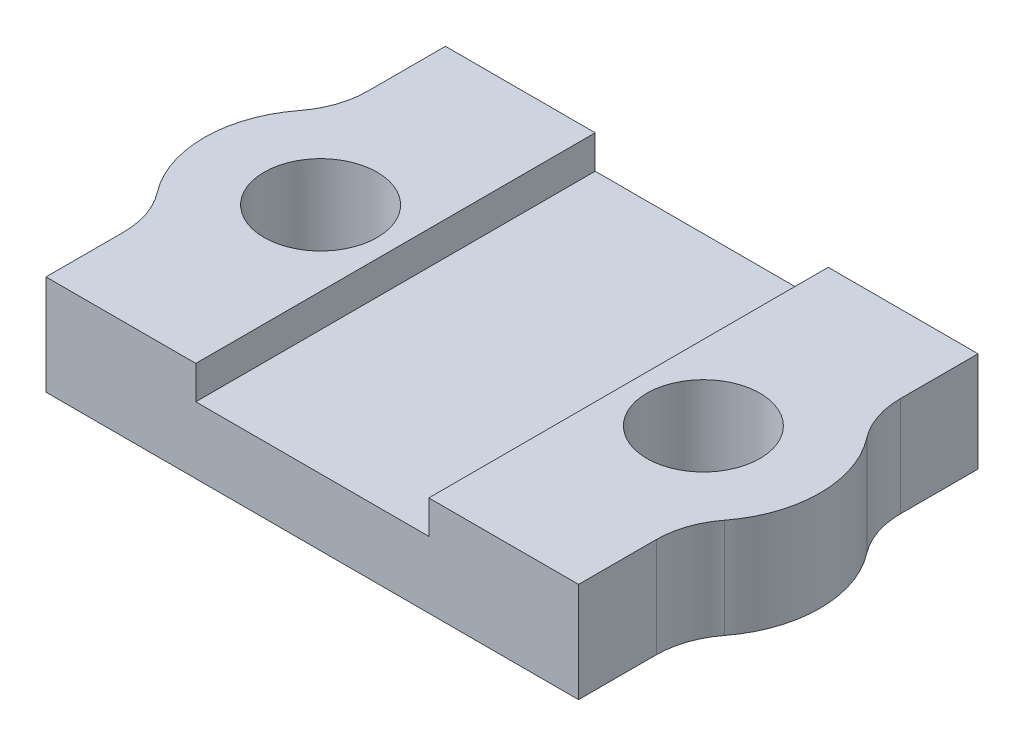
from build123d import *

# Parameters (mm, degrees)
CROQUIS1_R              = 1.7
SALIENTE_EXTRUIR1_DEPTH = 2
CROQUIS5_R              = 1.7
SALIENTE_EXTRUIR3_DEPTH = 1


with BuildPart() as part:
    # Croquis1 → Saliente-Extruir1 (new body)
    with BuildSketch(Plane(origin=(0, 0, 0), x_dir=(1, 0, 0), z_dir=(0, 1, 0))):
        with BuildLine():
            Line((-8, 6), (8, 6))
            Line((8, 6), (8, 3.665719575))
            ThreePointArc((8, 3.665719575), (8.133788189, 2.858848044), (8.520833333, 2.138336419))
            ThreePointArc((8.520833333, 2.138336419), (9.25, 0), (8.520833333, -2.138336419))
            ThreePointArc((8.520833333, -2.138336419), (8.133788189, -2.858848044), (8, -3.665719575))
            Line((8, -3.665719575), (8, -6))
            Line((8, -6), (-8, -6))
            Line((-8, -6), (-8, -3.665719575))
            ThreePointArc((-8, -3.665719575), (-8.133788189, -2.858848044), (-8.520833333, -2.138336419))
            ThreePointArc((-8.520833333, -2.138336419), (-9.25, 0), (-8.520833333, 2.138336419))
            ThreePointArc((-8.520833333, 2.138336419), (-8.133788189, 2.858848044), (-8, 3.665719575))
            Line((-8, 3.665719575), (-8, 6))
        make_face()
        with Locations((5.75, 0)):
            Circle(CROQUIS1_R, mode=Mode.SUBTRACT)
        with Locations((-5.75, 0)):
            Circle(CROQUIS1_R, mode=Mode.SUBTRACT)
    extrude(amount=SALIENTE_EXTRUIR1_DEPTH)

    # Croquis5 → Saliente-Extruir3 (add)
    with BuildSketch(Plane(origin=(0, 2, 0), x_dir=(1, 0, 0), z_dir=(0, 1, 0))):
        with BuildLine():
            Line((3.5, -6), (3.5, 6))
            Line((3.5, 6), (8, 6))
            Line((8, 6), (8, 3.665719575))
            ThreePointArc((8, 3.665719575), (8.133788189, 2.858848044), (8.520833333, 2.138336419))
            ThreePointArc((8.520833333, 2.138336419), (9.25, 0), (8.520833333, -2.138336419))
            ThreePointArc((8.520833333, -2.138336419), (8.133788189, -2.858848044), (8, -3.665719575))
            Line((8, -3.665719575), (8, -6))
            Line((8, -6), (3.5, -6))
        make_face()
        with Locations((5.75, 0)):
            Circle(CROQUIS5_R, mode=Mode.SUBTRACT)
    saliente_extruir3 = extrude(amount=SALIENTE_EXTRUIR3_DEPTH)

    # Simetría1: Saliente-Extruir3 across plane
    add(saliente_extruir3.mirror(Plane(origin=(0, 0, 0), x_dir=(0, 0, 1), z_dir=(1, 0, 0))))


solid = part.part
